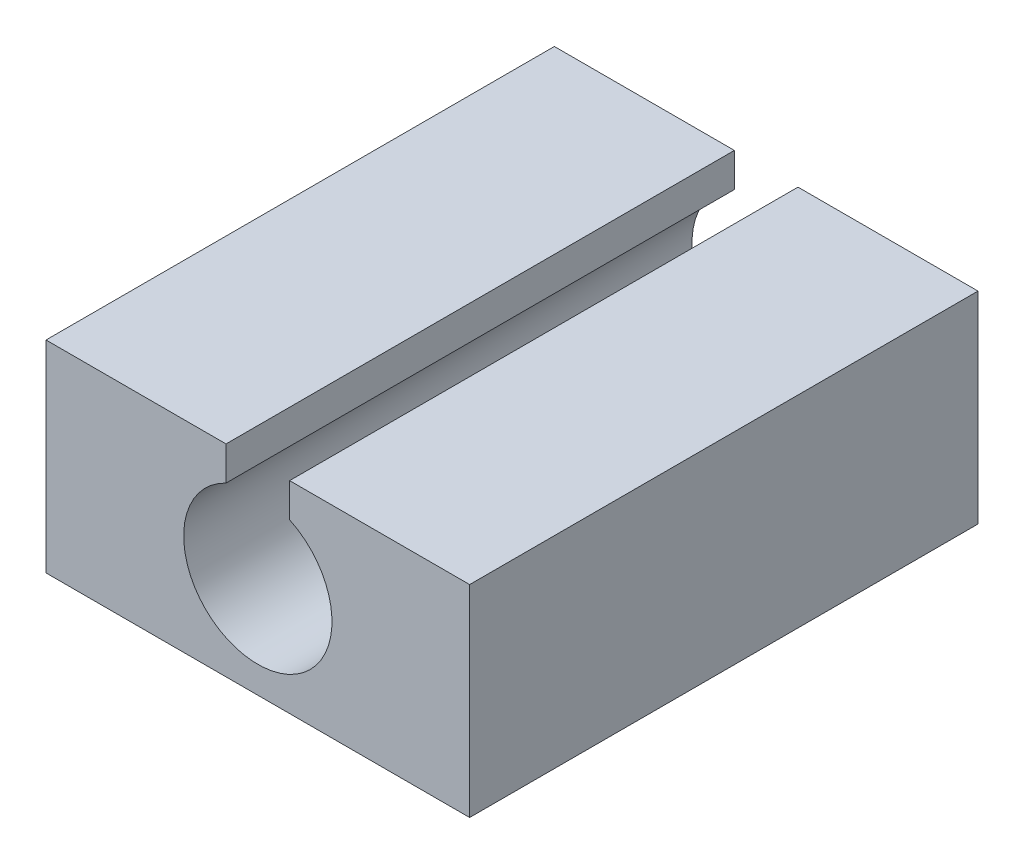
from build123d import *

# Parameters (mm, degrees)
SKETCH1_W           = 10
SKETCH1_H           = 12
BOSS_EXTRUDE1_DEPTH = 4.7625
SKETCH2_R           = 1.75
CUT_EXTRUDE1_DEPTH  = 12.7625
SKETCH4_W           = 1.501109308
SKETCH4_H           = 12
CUT_EXTRUDE2_DEPTH  = 1


with BuildPart() as part:
    # Sketch1 → Boss-Extrude1 (new body)
    with BuildSketch(Plane(origin=(0, 0, 0), x_dir=(1, 0, 0), z_dir=(0, 1, 0))):
        with Locations((5, 6)):
            Rectangle(SKETCH1_W, SKETCH1_H)
    extrude(amount=BOSS_EXTRUDE1_DEPTH)

    # Sketch2 → Cut-Extrude1 (cut)
    with BuildSketch(Plane.XY):
        with Locations((5, 2.38125)):
            Circle(SKETCH2_R)
    extrude(amount=-CUT_EXTRUDE1_DEPTH, mode=Mode.SUBTRACT)

    # Sketch4 → Cut-Extrude2 (cut)
    with BuildSketch(Plane(origin=(0, 4.7625, 0), x_dir=(1, 0, 0), z_dir=(0, 1, 0))):
        with Locations((5, 6)):
            Rectangle(SKETCH4_W, SKETCH4_H)
    extrude(amount=-CUT_EXTRUDE2_DEPTH, mode=Mode.SUBTRACT)


solid = part.part
